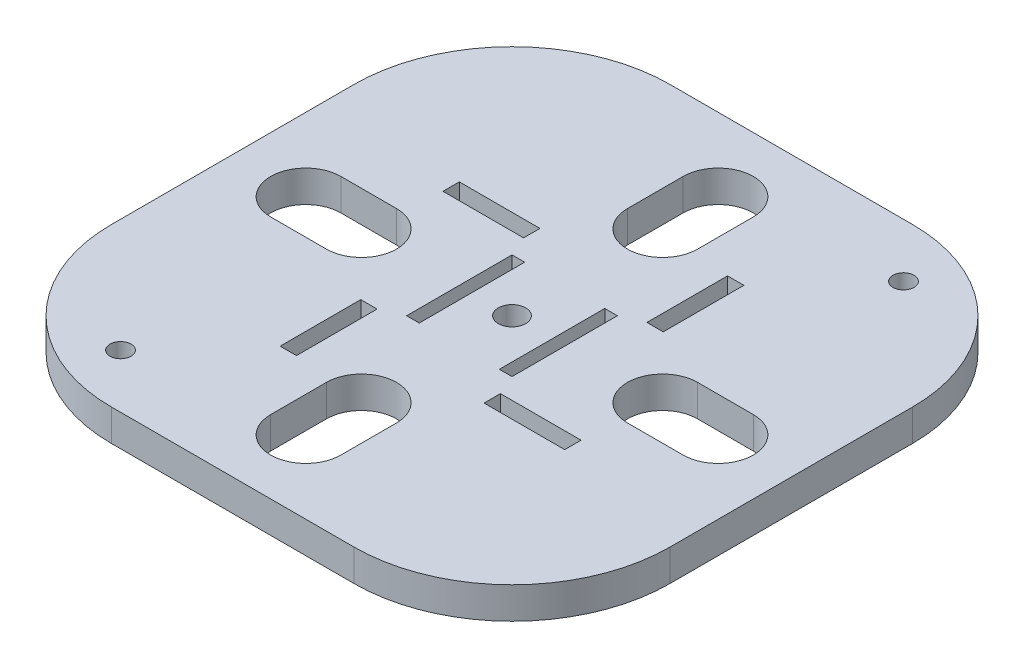
from build123d import *

# Parameters (mm, degrees)
ESBO_O1_W                = 53
ESBO_O1_H                = 53
RESSALTO_EXTRUS_O1_DEPTH = 3
ESBO_O3_R                = 1.3
ESBO_O3_W                = 1.2
ESBO_O3_H                = 10
CORTE_EXTRUS_O1_DEPTH    = 38.596542394
ESBO_O4_W                = 1.55
ESBO_O4_H                = 7.65
ESBO_O4_W_2              = 7.65
ESBO_O4_H_2              = 1.55
CORTE_EXTRUS_O2_DEPTH    = 10
FILETE1_R                = 15
ESBO_O5_R                = 1
CORTE_EXTRUS_O3_DEPTH    = 38.596542394


with BuildPart() as part:
    # Esboço1 → Ressalto-extrusão1 (new body)
    with BuildSketch(Plane(origin=(0, 0, 0), x_dir=(1, 0, 0), z_dir=(0, 1, 0))):
        Rectangle(ESBO_O1_W, ESBO_O1_H)
    extrude(amount=RESSALTO_EXTRUS_O1_DEPTH)

    # Esboço3 → Corte-extrusão1 (cut, through all)
    with BuildSketch(Plane(origin=(0, 3, 0), x_dir=(1, 0, 0), z_dir=(0, 1, 0))):
        with Locations(Location((0, 0, 0), (0, 0, 270))):
            Circle(ESBO_O3_R)
        with Locations((-4.4, 0)):
            Rectangle(ESBO_O3_W, ESBO_O3_H)
        with Locations((4.4, 0)):
            Rectangle(ESBO_O3_W, ESBO_O3_H)
    extrude(amount=-CORTE_EXTRUS_O1_DEPTH, mode=Mode.SUBTRACT)

    # Esboço4 → Corte-extrusão2 (cut)
    with BuildSketch(Plane(origin=(0, 3, 0), x_dir=(-1, 0, 0), z_dir=(0, 1, 0))):
        with Locations((-7.725, -9.675)):
            Rectangle(ESBO_O4_W, ESBO_O4_H)
        with Locations((-9.675, 7.725)):
            Rectangle(ESBO_O4_W_2, ESBO_O4_H_2)
        with Locations((7.725, 9.675)):
            Rectangle(ESBO_O4_W, ESBO_O4_H)
        with Locations((9.675, -7.725)):
            Rectangle(ESBO_O4_W_2, ESBO_O4_H_2)
    extrude(amount=-CORTE_EXTRUS_O2_DEPTH, mode=Mode.SUBTRACT)

    # Filete1
    filete1_edges = [part.edges().sort_by_distance(p)[0] for p in [
        (26.5, 1.5, 26.5),
        (-26.5, 1.5, 26.5),
        (-26.5, 1.5, -26.5),
        (26.5, 1.5, -26.5),
    ]]
    fillet(filete1_edges, radius=FILETE1_R)

    # Esboço5 → Corte-extrusão3 (cut, through all)
    with BuildSketch(Plane(origin=(0, 3, 0), x_dir=(1, 0, 0), z_dir=(0, 1, 0))):
        with Locations(Location((-15.742640687, -21.399494937, 0), (0, 0, 270))):
            Circle(ESBO_O5_R)
        with Locations(Location((15.742640687, 21.399494937, 0), (0, 0, 270))):
            Circle(ESBO_O5_R)
        with BuildLine():
            Line((19.566648228, -3.32990767), (14.283511733, -3.32990767))
            ThreePointArc((14.283511733, -3.32990767), (10.953604064, 0), (14.283511733, 3.32990767))
            Line((14.283511733, 3.32990767), (19.566648228, 3.32990767))
            ThreePointArc((19.566648228, 3.32990767), (22.896555897, 0), (19.566648228, -3.32990767))
        make_face()
        with BuildLine():
            Line((-3.32990767, -19.566648228), (-3.32990767, -14.283511733))
            ThreePointArc((-3.32990767, -14.283511733), (0, -10.953604064), (3.32990767, -14.283511733))
            Line((3.32990767, -14.283511733), (3.32990767, -19.566648228))
            ThreePointArc((3.32990767, -19.566648228), (0, -22.896555897), (-3.32990767, -19.566648228))
        make_face()
        with BuildLine():
            Line((-19.566648228, 3.32990767), (-14.283511733, 3.32990767))
            ThreePointArc((-14.283511733, 3.32990767), (-10.953604064, 0), (-14.283511733, -3.32990767))
            Line((-14.283511733, -3.32990767), (-19.566648228, -3.32990767))
            ThreePointArc((-19.566648228, -3.32990767), (-22.896555897, 0), (-19.566648228, 3.32990767))
        make_face()
        with BuildLine():
            Line((3.32990767, 19.566648228), (3.32990767, 14.283511733))
            ThreePointArc((3.32990767, 14.283511733), (0, 10.953604064), (-3.32990767, 14.283511733))
            Line((-3.32990767, 14.283511733), (-3.32990767, 19.566648228))
            ThreePointArc((-3.32990767, 19.566648228), (0, 22.896555897), (3.32990767, 19.566648228))
        make_face()
    extrude(amount=-CORTE_EXTRUS_O3_DEPTH, mode=Mode.SUBTRACT)


solid = part.part
